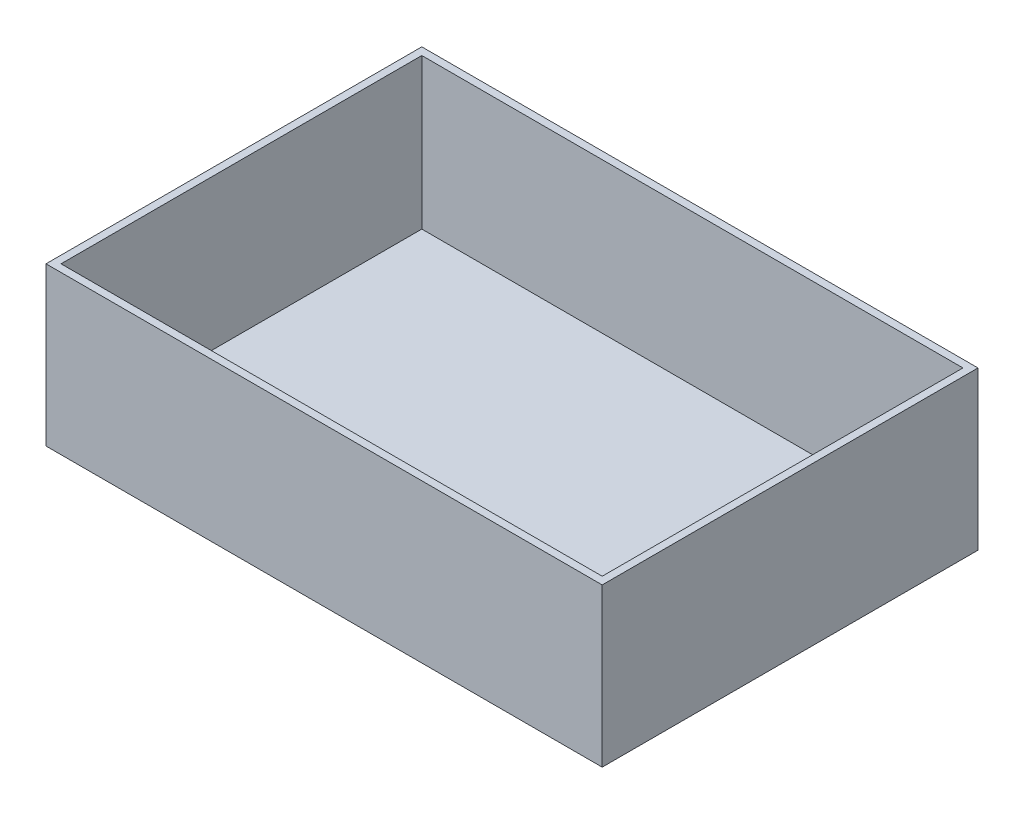
from build123d import *

# Parameters (mm, degrees)
SKETCH1_W           = 370
SKETCH1_H           = 250
SKETCH1_W_2         = 360
SKETCH1_H_2         = 240
BOSS_EXTRUDE1_DEPTH = 100
SKETCH2_W           = 370
SKETCH2_H           = 250
BOSS_EXTRUDE2_DEPTH = 5


with BuildPart() as part:
    # Sketch1 → Boss-Extrude1 (new body)
    with BuildSketch(Plane(origin=(0, 0, 0), x_dir=(1, 0, 0), z_dir=(0, 1, 0))):
        Rectangle(SKETCH1_W, SKETCH1_H)
        Rectangle(SKETCH1_W_2, SKETCH1_H_2, mode=Mode.SUBTRACT)
    extrude(amount=BOSS_EXTRUDE1_DEPTH)

    # Sketch2 → Boss-Extrude2 (add)
    with BuildSketch(Plane.XZ):
        Rectangle(SKETCH2_W, SKETCH2_H)
    extrude(amount=BOSS_EXTRUDE2_DEPTH)


solid = part.part
